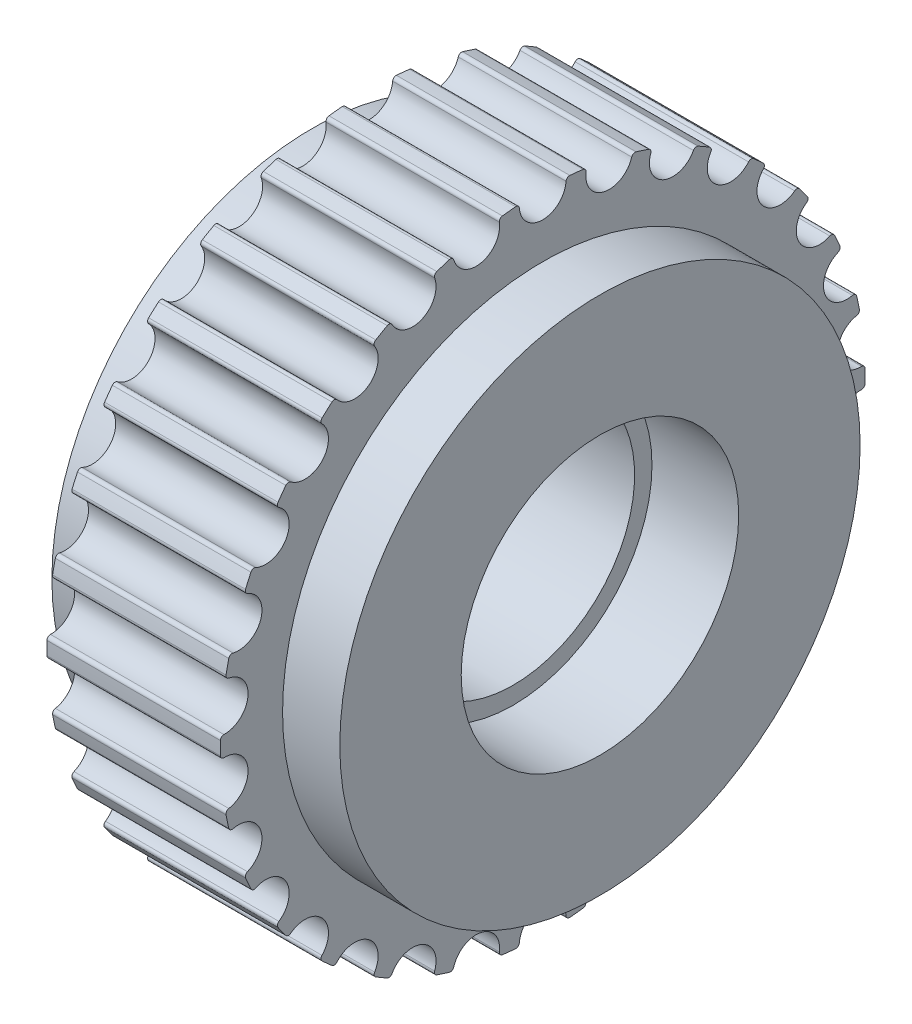
from build123d import *

# Parameters (mm, degrees)
CUT_EXTRUDE2_DEPTH       = 9.3
FILLET3_R                = 0.1
CIRPATTERN2_COUNT        = 30
FILLET3_OF_CIRPATTERN2_R = 0.1


with BuildPart() as part:
    # Sketch1 → Revolve1 (revolve)
    with BuildSketch(Plane.XY):
        Polygon((0, 4), (2.5, 4), (2.5, 3.5), (5.8, 3.5), (5.8, 4), (8.3, 4), (8.3, 7.5), (6.65, 7.5), (6.65, 9.295), (1.65, 9.295), (1.65, 7.5), (0, 7.5), align=None)
    revolve(axis=Axis((0, 0, 0), (1, 0, 0)))

    # Sketch3 → Cut-Extrude2 (cut, through all)
    with BuildSketch(Plane.ZY):
        with BuildLine():
            ThreePointArc((-0.673101026, 9.270596529), (0, 8.545), (0.673101026, 9.270596529))
            ThreePointArc((0.673101026, 9.270596529), (0, 9.295), (-0.673101026, 9.270596529))
        make_face()
    cut_extrude2 = extrude(amount=-CUT_EXTRUDE2_DEPTH, mode=Mode.SUBTRACT)

    # Fillet3
    fillet3_edges = [part.edges().sort_by_distance(p)[0] for p in [
        (4.15, 9.270596529, -0.673101026),
        (4.15, 9.270596529, 0.673101026),
    ]]
    fillet(fillet3_edges, radius=FILLET3_R)

    # CirPattern2: Cut-Extrude2 ×30 about axis
    cirpattern2_axis = Axis((0, 0, 0), (1, 0, 0))
    for i in range(1, CIRPATTERN2_COUNT):
        add(cut_extrude2.rotate(cirpattern2_axis, i * 360 / CIRPATTERN2_COUNT), mode=Mode.SUBTRACT)

    # Fillet3 of CirPattern2
    fillet3_of_cirpattern2_edges = [part.edges().sort_by_distance(p)[0] for p in [
        (4.15, 9.207957325, 1.269073246),
        (4.15, 8.92806618, 2.585857553),
        (4.15, 8.742886201, 3.155782927),
        (4.15, 8.195336497, 4.385599696),
        (4.15, 7.895708997, 4.904569751),
        (4.15, 7.104431284, 5.993670089),
        (4.15, 6.703451421, 6.439003342),
        (4.15, 5.703028332, 7.339788338),
        (4.15, 5.218220852, 7.69202159),
        (4.15, 4.052375677, 8.365122616),
        (4.15, 3.504928992, 8.608861583),
        (4.15, 2.224614759, 9.024860895),
        (4.15, 1.638454917, 9.149453016),
        (4.15, 0.299627501, 9.290169447),
        (4.15, -0.299627501, 9.290169447),
        (4.15, -1.638454917, 9.149453016),
        (4.15, -2.224614759, 9.024860895),
        (4.15, -3.504928992, 8.608861583),
        (4.15, -4.052375677, 8.365122616),
        (4.15, -5.218220852, 7.69202159),
        (4.15, -5.703028332, 7.339788338),
        (4.15, -6.703451421, 6.439003342),
        (4.15, -7.104431284, 5.993670089),
        (4.15, -7.895708997, 4.904569751),
        (4.15, -8.195336497, 4.385599696),
        (4.15, -8.742886201, 3.155782927),
        (4.15, -8.92806618, 2.585857553),
        (4.15, -9.207957325, 1.269073246),
        (4.15, -9.270596529, 0.673101026),
        (4.15, -9.270596529, -0.673101026),
        (4.15, -9.207957325, -1.269073246),
        (4.15, -8.92806618, -2.585857553),
        (4.15, -8.742886201, -3.155782927),
        (4.15, -8.195336497, -4.385599696),
        (4.15, -7.895708997, -4.904569751),
        (4.15, -7.104431284, -5.993670089),
        (4.15, -6.703451421, -6.439003342),
        (4.15, -5.703028332, -7.339788338),
        (4.15, -5.218220852, -7.69202159),
        (4.15, -4.052375677, -8.365122616),
        (4.15, -3.504928992, -8.608861583),
        (4.15, -2.224614759, -9.024860895),
        (4.15, -1.638454917, -9.149453016),
        (4.15, -0.299627501, -9.290169447),
        (4.15, 0.299627501, -9.290169447),
        (4.15, 1.638454917, -9.149453016),
        (4.15, 2.224614759, -9.024860895),
        (4.15, 3.504928992, -8.608861583),
        (4.15, 4.052375677, -8.365122616),
        (4.15, 5.218220852, -7.69202159),
        (4.15, 5.703028332, -7.339788338),
        (4.15, 6.703451421, -6.439003342),
        (4.15, 7.104431284, -5.993670089),
        (4.15, 7.895708997, -4.904569751),
        (4.15, 8.195336497, -4.385599696),
        (4.15, 8.742886201, -3.155782927),
        (4.15, 8.92806618, -2.585857553),
        (4.15, 9.207957325, -1.269073246),
    ]]
    fillet(fillet3_of_cirpattern2_edges, radius=FILLET3_OF_CIRPATTERN2_R)


solid = part.part
